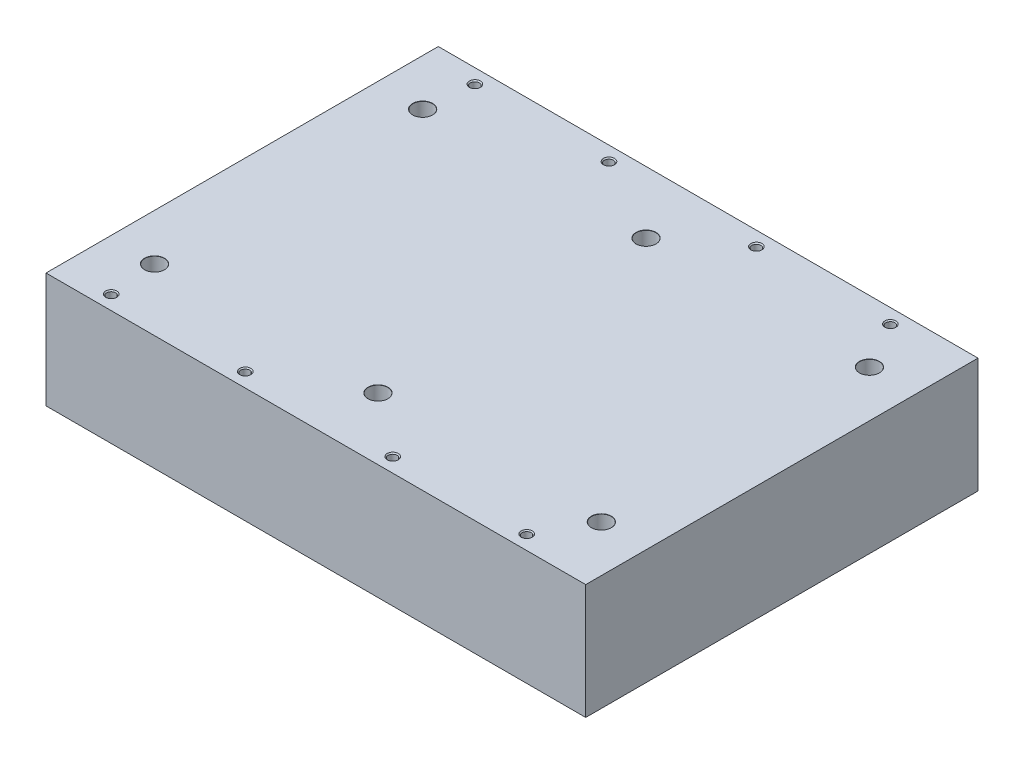
from build123d import *

# Parameters (mm, degrees)
SKETCH1_W                       = 302
SKETCH1_H                       = 219.5
BOSS_EXTRUDE1_DEPTH             = 64.4
M6X1_0_TAPPED_HOLE1_D           = 5
M6X1_0_TAPPED_HOLE1_DEPTH       = 16
M6X1_0_TAPPED_HOLE1_CSINK_D     = 6.2
M6X1_0_TAPPED_HOLE1_CSINK_ANGLE = 90
M6X1_0_TAPPED_HOLE1_TIP         = 1.502151548
CBORE_FOR_M6_SHCS1_AT_2_COUNT   = 2
CBORE_FOR_M6_SHCS1_AT_2_PITCH   = 150
CBORE_FOR_M6_SHCS1_AT_3_COUNT   = 2
CBORE_FOR_M6_SHCS1_AT_3_PITCH   = 195.256241898
CBORE_FOR_M6_SHCS1_AT_4_COUNT   = 2
CBORE_FOR_M6_SHCS1_AT_4_PITCH   = 125
CBORE_FOR_M6_SHCS1_AT_5_COUNT   = 2
CBORE_FOR_M6_SHCS1_AT_5_PITCH   = 250
CBORE_FOR_M6_SHCS1_AT_6_COUNT   = 2
CBORE_FOR_M6_SHCS1_AT_6_PITCH   = 291.547594742


with BuildPart() as part:
    # Sketch1 → Boss-Extrude1 (new body)
    with BuildSketch(Plane(origin=(0, 0, 0), x_dir=(1, 0, 0), z_dir=(0, 1, 0))):
        with Locations((151, 109.75)):
            Rectangle(SKETCH1_W, SKETCH1_H)
    extrude(amount=BOSS_EXTRUDE1_DEPTH)

    # M6x1.0 Tapped Hole1
    with Locations(Plane(origin=(0, 64.4, 0), x_dir=(1, 0, 0), z_dir=(0, 1, 0))):
        with Locations((28.5, 8), (103.5, 8), (186, 8), (261, 8), (261, 211.5), (186, 211.5), (103.5, 211.5), (28.5, 211.5)):
            CounterSinkHole(M6X1_0_TAPPED_HOLE1_D / 2, M6X1_0_TAPPED_HOLE1_CSINK_D / 2, depth=M6X1_0_TAPPED_HOLE1_DEPTH, counter_sink_angle=M6X1_0_TAPPED_HOLE1_CSINK_ANGLE)
            with Locations((0, 0, -(M6X1_0_TAPPED_HOLE1_DEPTH + M6X1_0_TAPPED_HOLE1_TIP / 2))):  # 118° drill point
                Cone(0, M6X1_0_TAPPED_HOLE1_D / 2, M6X1_0_TAPPED_HOLE1_TIP, mode=Mode.SUBTRACT)

    # Sketch5 → CBORE for M6 SHCS1 (revolve, cut)
    with BuildSketch(Plane(origin=(26, 64.4, -34.75), x_dir=(0, 0, 1), z_dir=(1, 0, 0))):
        Polygon((0, 0), (0, 64.4), (3.2, 64.4), (3.2, 20), (5.5, 20), (5.5, 0.1), (5.6, 0), align=None)
    cbore_for_m6_shcs1 = revolve(axis=Axis((26, 70.75, -34.75), (0, -1, 0)), mode=Mode.SUBTRACT)

    # CBORE for M6 SHCS1 at 2: CBORE for M6 SHCS1 ×2
    with Locations(*[(0, 0, -i * CBORE_FOR_M6_SHCS1_AT_2_PITCH) for i in range(1, CBORE_FOR_M6_SHCS1_AT_2_COUNT)]):
        add(cbore_for_m6_shcs1, mode=Mode.SUBTRACT)

    # CBORE for M6 SHCS1 at 3: CBORE for M6 SHCS1 ×2
    with Locations(*[Vector(0.6401844, 0, -0.76822128) * (i * CBORE_FOR_M6_SHCS1_AT_3_PITCH) for i in range(1, CBORE_FOR_M6_SHCS1_AT_3_COUNT)]):
        add(cbore_for_m6_shcs1, mode=Mode.SUBTRACT)

    # CBORE for M6 SHCS1 at 4: CBORE for M6 SHCS1 ×2
    with Locations(*[(i * CBORE_FOR_M6_SHCS1_AT_4_PITCH, 0, 0) for i in range(1, CBORE_FOR_M6_SHCS1_AT_4_COUNT)]):
        add(cbore_for_m6_shcs1, mode=Mode.SUBTRACT)

    # CBORE for M6 SHCS1 at 5: CBORE for M6 SHCS1 ×2
    with Locations(*[(i * CBORE_FOR_M6_SHCS1_AT_5_PITCH, 0, 0) for i in range(1, CBORE_FOR_M6_SHCS1_AT_5_COUNT)]):
        add(cbore_for_m6_shcs1, mode=Mode.SUBTRACT)

    # CBORE for M6 SHCS1 at 6: CBORE for M6 SHCS1 ×2
    with Locations(*[Vector(0.857492926, 0, -0.514495755) * (i * CBORE_FOR_M6_SHCS1_AT_6_PITCH) for i in range(1, CBORE_FOR_M6_SHCS1_AT_6_COUNT)]):
        add(cbore_for_m6_shcs1, mode=Mode.SUBTRACT)


solid = part.part
